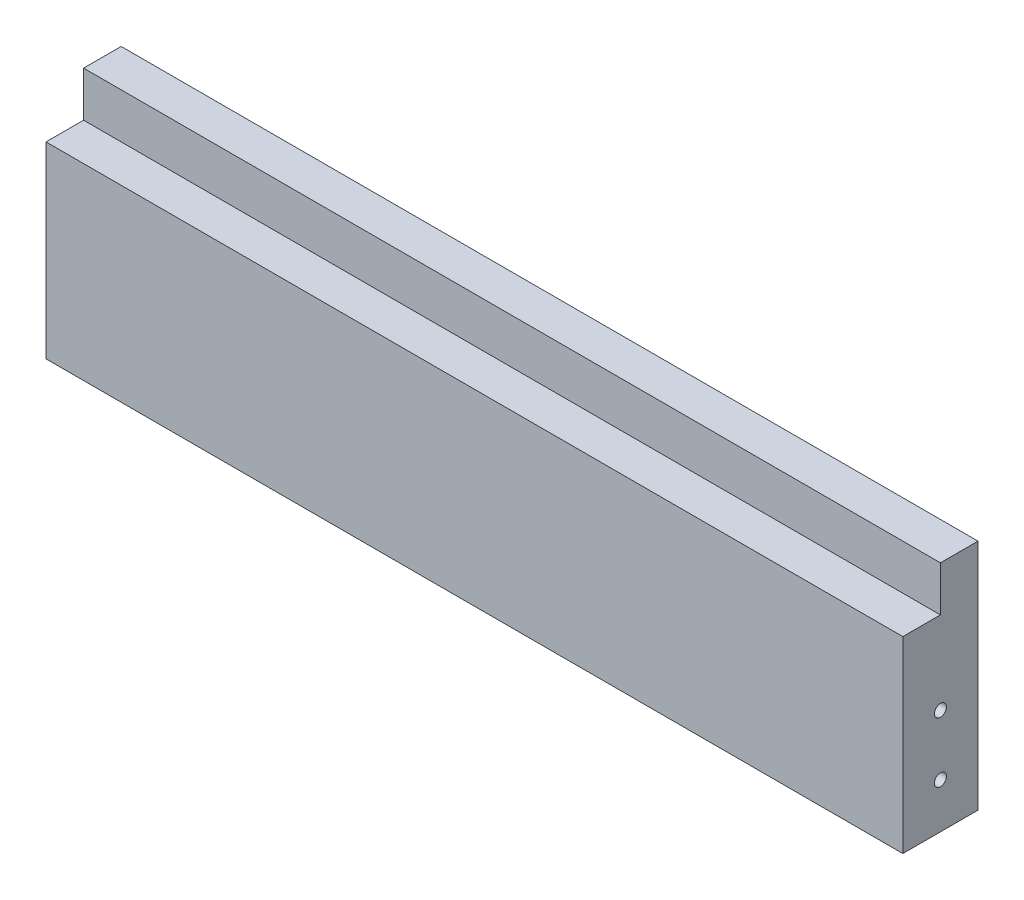
from build123d import *

# Parameters (mm, degrees)
SKETCH1_W                 = 114
SKETCH1_H                 = 31
BOSS_EXTRUDE1_DEPTH       = 10
SKETCH2_W                 = 114
SKETCH2_H                 = 6
CUT_EXTRUDE1_DEPTH        = 5
M2X0_4_TAPPED_HOLE1_D     = 1.6
M2X0_4_TAPPED_HOLE1_DEPTH = 7
M2X0_4_TAPPED_HOLE1_TIP   = 0.480688495
M2X0_4_TAPPED_HOLE3_D     = 1.6
M2X0_4_TAPPED_HOLE3_DEPTH = 7
M2X0_4_TAPPED_HOLE3_TIP   = 0.480688495
M2X0_4_TAPPED_HOLE2_D     = 1.6
M2X0_4_TAPPED_HOLE2_DEPTH = 7
M2X0_4_TAPPED_HOLE2_TIP   = 0.480688495


with BuildPart() as part:
    # Sketch1 → Boss-Extrude1 (new body)
    with BuildSketch(Plane.XY):
        with Locations((57, 15.5)):
            Rectangle(SKETCH1_W, SKETCH1_H)
    extrude(amount=BOSS_EXTRUDE1_DEPTH)

    # Sketch2 → Cut-Extrude1 (cut)
    with BuildSketch(Plane.XY.offset(10)):
        with Locations((57, 28)):
            Rectangle(SKETCH2_W, SKETCH2_H)
    extrude(amount=-CUT_EXTRUDE1_DEPTH, mode=Mode.SUBTRACT)

    # M2x0.4 Tapped Hole1
    with Locations(Plane(origin=(0, 14, 5), x_dir=(0, 0, -1), z_dir=(-1, 0, 0))):
        with Locations((0, 0), (0, 8)):
            Hole(M2X0_4_TAPPED_HOLE1_D / 2, depth=M2X0_4_TAPPED_HOLE1_DEPTH)
            with Locations((0, 0, -(M2X0_4_TAPPED_HOLE1_DEPTH + M2X0_4_TAPPED_HOLE1_TIP / 2))):  # 118° drill point
                Cone(0, M2X0_4_TAPPED_HOLE1_D / 2, M2X0_4_TAPPED_HOLE1_TIP, mode=Mode.SUBTRACT)

    # M2x0.4 Tapped Hole3
    with Locations(Plane(origin=(114, 14, 5), x_dir=(0, 0, 1), z_dir=(1, 0, 0))):
        with Locations((0, 0), (0, 8)):
            Hole(M2X0_4_TAPPED_HOLE3_D / 2, depth=M2X0_4_TAPPED_HOLE3_DEPTH)
            with Locations((0, 0, -(M2X0_4_TAPPED_HOLE3_DEPTH + M2X0_4_TAPPED_HOLE3_TIP / 2))):  # 118° drill point
                Cone(0, M2X0_4_TAPPED_HOLE3_D / 2, M2X0_4_TAPPED_HOLE3_TIP, mode=Mode.SUBTRACT)

    # M2x0.4 Tapped Hole2
    with Locations(Plane(origin=(0, 0, 0), x_dir=(-1, 0, 0), z_dir=(0, -1, 0))):
        with Locations((-102, -5), (-12, -5), (-57, -5), (-79, -5), (-35, -5)):
            Hole(M2X0_4_TAPPED_HOLE2_D / 2, depth=M2X0_4_TAPPED_HOLE2_DEPTH)
            with Locations((0, 0, -(M2X0_4_TAPPED_HOLE2_DEPTH + M2X0_4_TAPPED_HOLE2_TIP / 2))):  # 118° drill point
                Cone(0, M2X0_4_TAPPED_HOLE2_D / 2, M2X0_4_TAPPED_HOLE2_TIP, mode=Mode.SUBTRACT)


solid = part.part
